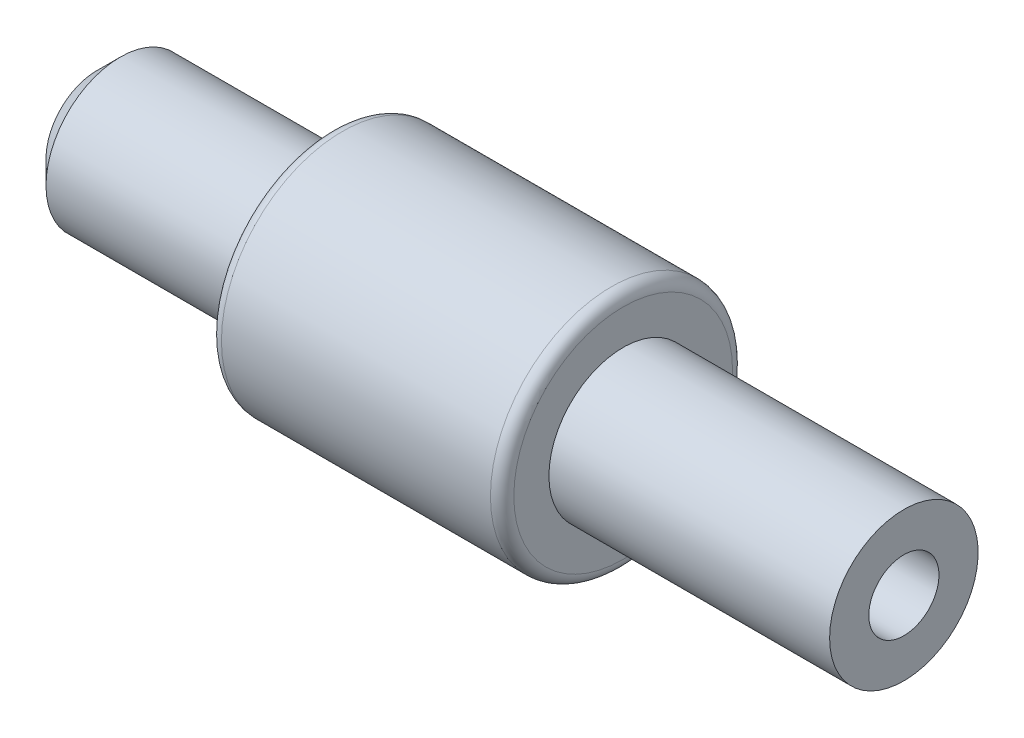
from build123d import *

# Parameters (mm, degrees)
CHAMFER1_SIZE = 1
FILLET1_R     = 0.5


with BuildPart() as part:
    # Sketch1 → Revolve1 (revolve)
    with BuildSketch(Plane.XY):
        Polygon((24.5, 3.175), (12.5, 3.175), (12.5, 5.175), (0, 5.175), (0, 3.175), (-10, 3.175), (-10, 1.5), (24.5, 1.5), align=None)
    revolve(axis=Axis((-42.941315625, 0, 0), (1, 0, 0)))

    # Chamfer1
    chamfer1_edges = [part.edges().sort_by_distance(p)[0] for p in [
        (-10, -3.175, 0),
    ]]
    chamfer(chamfer1_edges, length=CHAMFER1_SIZE)

    # Fillet1
    fillet1_edges = [part.edges().sort_by_distance(p)[0] for p in [
        (0, -5.175, 0),
        (12.5, -5.175, 0),
    ]]
    fillet(fillet1_edges, radius=FILLET1_R)


solid = part.part
